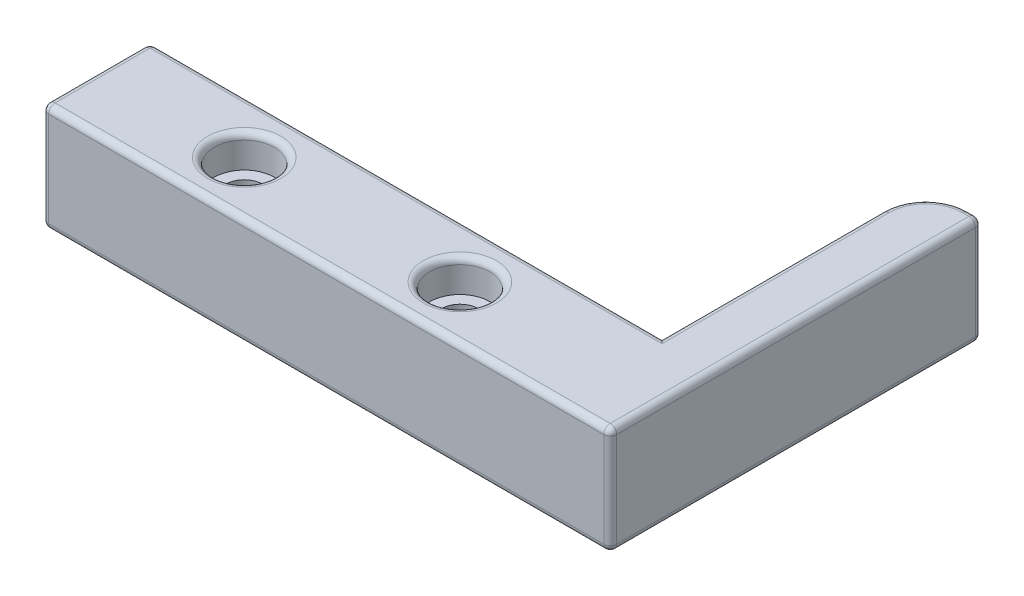
from build123d import *

# Parameters (mm, degrees)
SKETCH1_W           = 60.325
SKETCH1_H           = 12.7
SKETCH1_R           = 2.159
BOSS_EXTRUDE1_DEPTH = 12.7
SKETCH5_W           = 43.775259309
SKETCH5_H           = 12.7
BOSS_EXTRUDE3_DEPTH = 6.604
SKETCH6_R           = 3.556
CUT_EXTRUDE1_DEPTH  = 3.81
FILLET2_R           = 5.08
FILLET3_R           = 0.762


with BuildPart() as part:
    # Sketch1 → Boss-Extrude1 (new body)
    with BuildSketch(Plane(origin=(0, 0, 0), x_dir=(1, 0, 0), z_dir=(0, 1, 0))):
        with Locations((30.1625, 6.35)):
            Rectangle(SKETCH1_W, SKETCH1_H)
        with Locations((17.4625, 6.35)):
            Circle(SKETCH1_R, mode=Mode.SUBTRACT)
        with Locations((42.8625, 6.35)):
            Circle(SKETCH1_R, mode=Mode.SUBTRACT)
    extrude(amount=BOSS_EXTRUDE1_DEPTH)

    # Sketch5 → Boss-Extrude3 (add)
    with BuildSketch(Plane(origin=(60.325, 0, 0), x_dir=(0, 0, -1), z_dir=(1, 0, 0))):
        with Locations((21.887629655, 6.35)):
            Rectangle(SKETCH5_W, SKETCH5_H)
    extrude(amount=BOSS_EXTRUDE3_DEPTH)

    # Sketch6 → Cut-Extrude1 (cut)
    with BuildSketch(Plane(origin=(0, 12.7, 0), x_dir=(1, 0, 0), z_dir=(0, 1, 0))):
        with Locations((42.8625, 6.35)):
            Circle(SKETCH6_R)
        with Locations((17.4625, 6.35)):
            Circle(SKETCH6_R)
    extrude(amount=-CUT_EXTRUDE1_DEPTH, mode=Mode.SUBTRACT)

    # Fillet2
    fillet2_edges = [part.edges().sort_by_distance(p)[0] for p in [
        (60.325, 6.35, -43.775259309),
    ]]
    fillet(fillet2_edges, radius=FILLET2_R)

    # Fillet3
    fillet3_edges = [part.edges().sort_by_distance(p)[0] for p in [
        (30.1625, 12.7, -12.7),
        (60.325, 0, -25.697629654),
        (66.167, 0, -43.775259309),
        (66.167, 12.7, -43.775259309),
        (66.929, 6.35, 0),
        (66.929, 0, -21.887629654),
        (66.929, 6.35, -43.775259309),
        (66.929, 12.7, -21.887629654),
        (39.3065, 12.7, -6.35),
        (0, 12.7, -6.35),
        (13.9065, 12.7, -6.35),
        (30.1625, 0, -12.7),
        (60.325, 12.7, -25.697629654),
        (61.812897552, 12.7, -42.287361757),
        (61.812897552, 0, -42.287361757),
        (33.4645, 0, 0),
        (0, 0, -6.35),
        (33.4645, 12.7, 0),
        (0, 6.35, -12.7),
        (0, 6.35, 0),
    ]]
    fillet(fillet3_edges, radius=FILLET3_R)


solid = part.part
